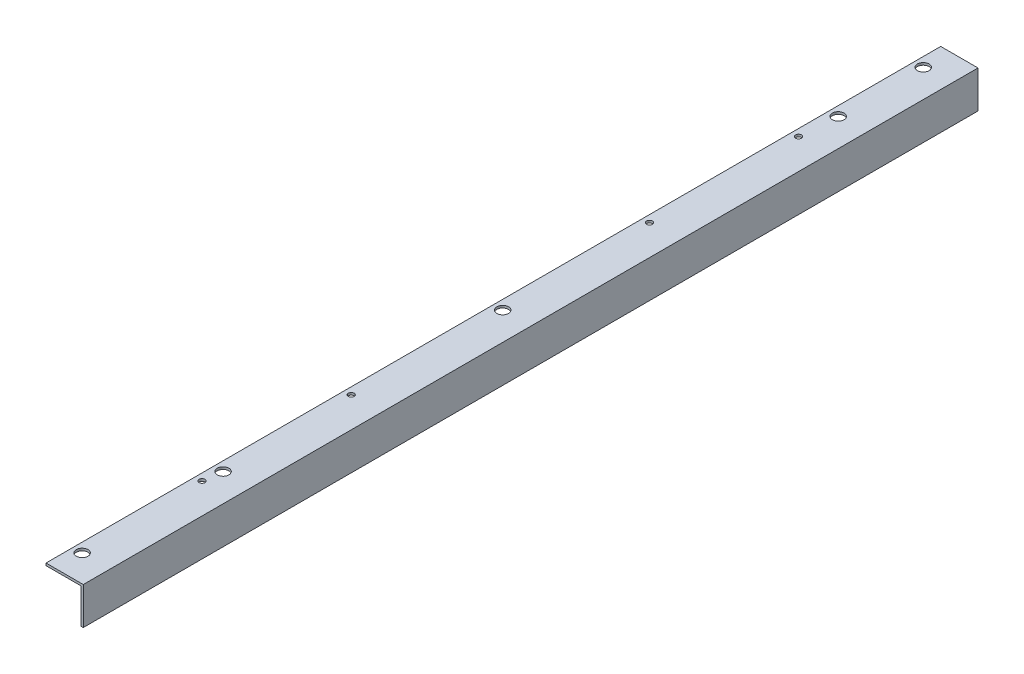
from build123d import *

# Parameters (mm, degrees)
BOSS_EXTRUDE1_DEPTH = 1219.2
SKETCH2_R           = 7.9375
CUT_EXTRUDE1_DEPTH  = 51.8
SKETCH4_R           = 3.96875
CUT_EXTRUDE3_DEPTH  = 44.45
LPATTERN1_COUNT     = 5
LPATTERN1_PITCH     = 203.2


with BuildPart() as part:
    # Sketch1 → Boss-Extrude1 (new body)
    with BuildSketch(Plane.XY):
        Polygon((0, 0), (-50.8, 0), (-50.8, -3.175), (-3.175, -3.175), (-3.175, -50.8), (0, -50.8), align=None)
    extrude(amount=BOSS_EXTRUDE1_DEPTH)

    # Sketch2 → Cut-Extrude1 (cut, through all)
    with BuildSketch(Plane(origin=(0, 0, 0), x_dir=(1, 0, 0), z_dir=(0, 1, 0))):
        with Locations((-38.1, -36.5125)):
            Circle(SKETCH2_R)
        with Locations((-38.1, -1182.6875)):
            Circle(SKETCH2_R)
        with Locations((-38.1, -152.4)):
            Circle(SKETCH2_R)
        with Locations((-38.1, -609.6)):
            Circle(SKETCH2_R)
        with Locations((-38.1, -990.6)):
            Circle(SKETCH2_R)
    extrude(amount=-CUT_EXTRUDE1_DEPTH, mode=Mode.SUBTRACT)

    # Sketch4 → Cut-Extrude3 (cut)
    with BuildSketch(Plane(origin=(-2.029899632, 0, 893.163272881), x_dir=(1, 0, 0), z_dir=(0, 1, 0))):
        with Locations((-39.245100368, 689.963272881)):
            Circle(SKETCH4_R)
    cut_extrude3 = extrude(amount=-CUT_EXTRUDE3_DEPTH, mode=Mode.SUBTRACT)

    # LPattern1: Cut-Extrude3 ×5, 1 skipped
    with Locations(*[(0, 0, i * LPATTERN1_PITCH) for i in range(1, LPATTERN1_COUNT) if i not in (2,)]):
        add(cut_extrude3, mode=Mode.SUBTRACT)


solid = part.part
